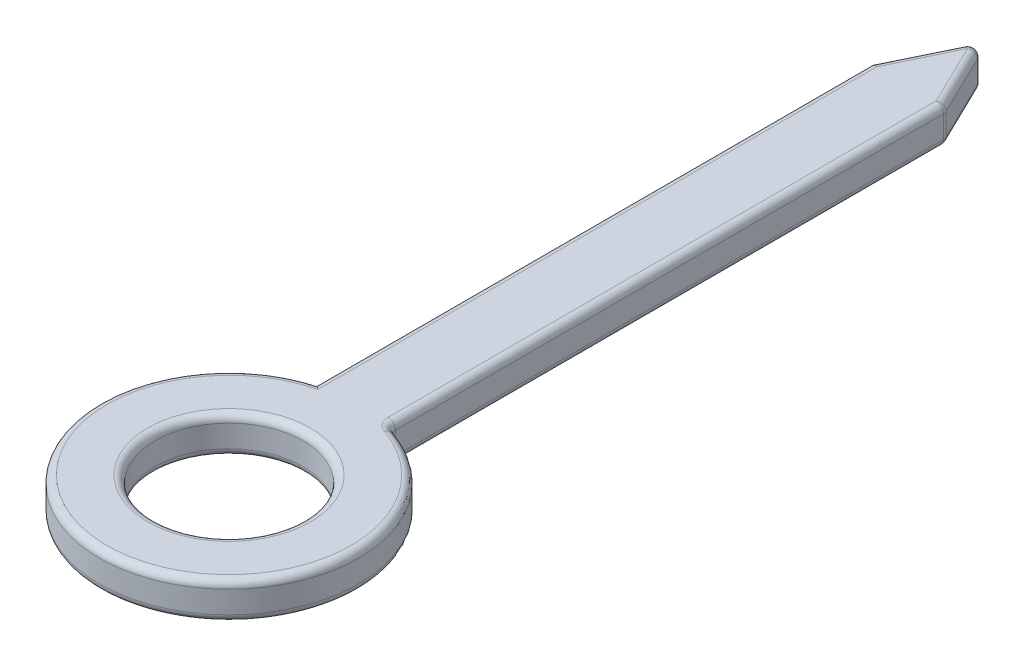
from build123d import *

# Parameters (mm, degrees)
SKETCH1_R      = 0.254
EXTRUDE1_DEPTH = 0.127
FILLET1_R      = 0.0254


with BuildPart() as part:
    # Sketch1 → Extrude1 (new body)
    with BuildSketch(Plane(origin=(0, 0, 0), x_dir=(1, 0, 0), z_dir=(0, 1, 0))):
        with BuildLine():
            Line((-0.127, 2.33097095), (0, 2.592734318))
            Line((0, 2.592734318), (0.127, 2.33097095))
            Line((0.127, 2.33097095), (0.127, 0.42597095))
            ThreePointArc((0.127, 0.42597095), (0, -0.4445), (-0.127, 0.42597095))
            Line((-0.127, 0.42597095), (-0.127, 2.33097095))
        make_face()
        Circle(SKETCH1_R, mode=Mode.SUBTRACT)
    extrude(amount=EXTRUDE1_DEPTH)

    # Fillet1
    fillet1_edges = [part.edges().sort_by_distance(p)[0] for p in [
        (0.0635, 0.127, -2.461852634),
        (-0.0635, 0.127, -2.461852634),
        (-0.254, 0, 0),
        (-0.254, 0.127, 0),
        (-0.127, 0.127, -1.37847095),
        (0, 0.127, 0.4445),
        (-0.127, 0, -1.37847095),
        (-0.0635, 0, -2.461852634),
        (0.0635, 0, -2.461852634),
        (0.127, 0, -1.37847095),
        (0, 0, 0.4445),
        (0.127, 0.127, -1.37847095),
        (0, 0.0635, -2.592734318),
        (0.127, 0.0635, -2.33097095),
        (0.127, 0.0635, -0.42597095),
    ]]
    fillet(fillet1_edges, radius=FILLET1_R)


solid = part.part
